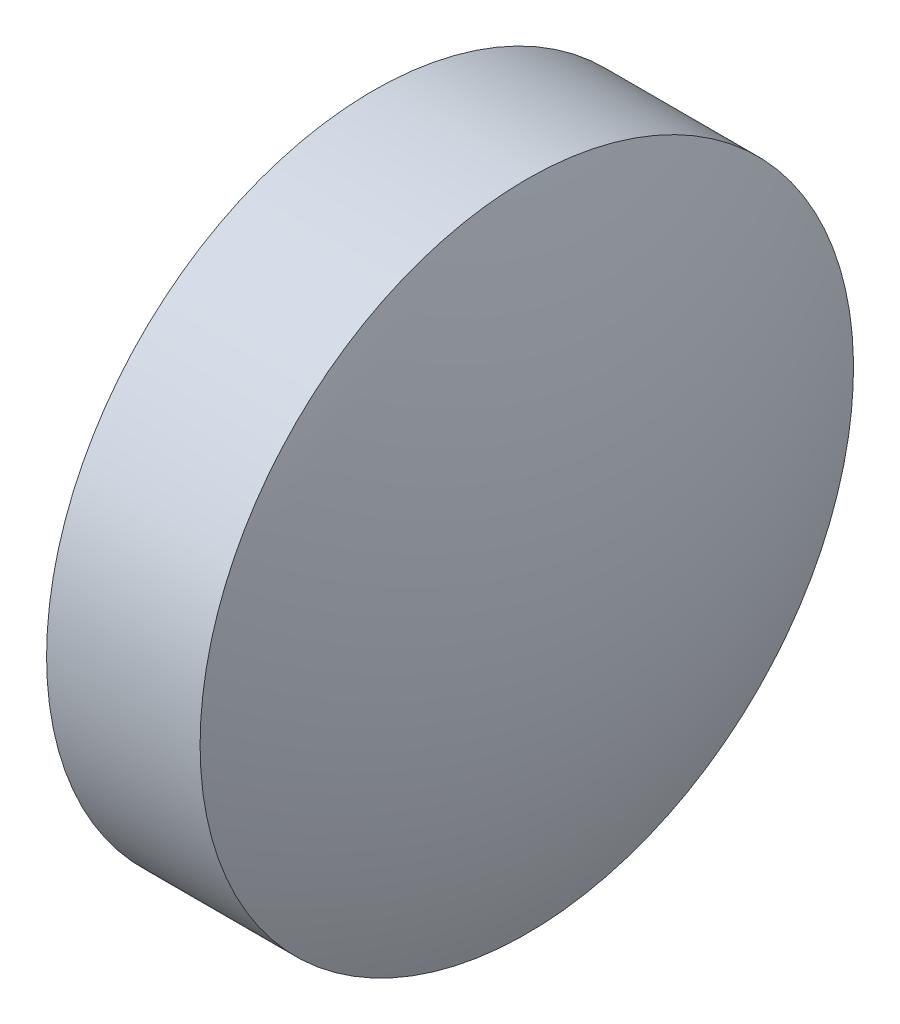
from build123d import *


with BuildPart() as part:
    # 草图1 → 旋转1 (revolve)
    with BuildSketch(Plane.XY):
        with BuildLine():
            Line((443.023371252, -98.439729515), (443.023371252, -95.289729515))
            Line((443.023371252, -95.289729515), (444.503371252, -95.289729515))
            ThreePointArc((444.503371252, -95.289729515), (444.966898461, -96.834511461), (445.123371252, -98.439729515))
            Line((445.123371252, -98.439729515), (443.023371252, -98.439729515))
        make_face()
    revolve(axis=Axis((442.21766084, -98.439729515, 0), (1, 0, 0)))


solid = part.part
